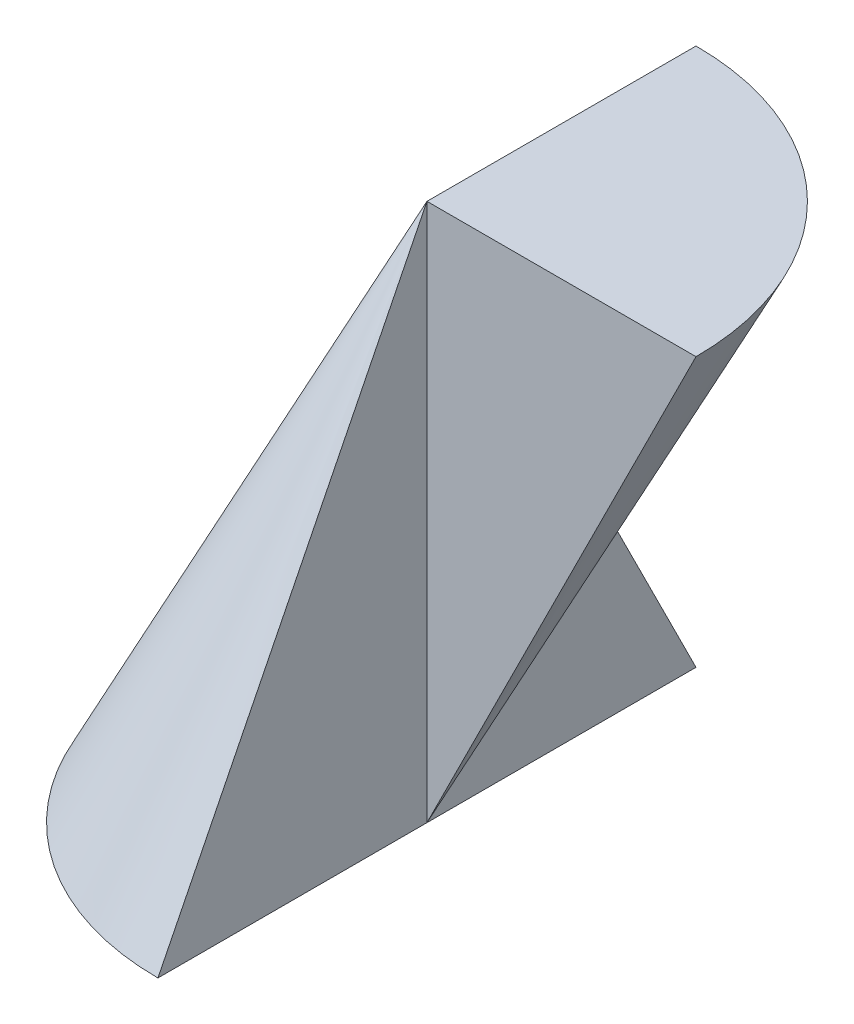
from build123d import *

# Parameters (mm, degrees)
REVOLVE1_ANGLE = 180
REVOLVE2_ANGLE = 90


with BuildPart() as part:
    # Sketch1 → Revolve1 (revolve)
    with BuildSketch(Plane(origin=(0, 0, 0), x_dir=(0, 0, -1), z_dir=(1, 0, 0))):
        Polygon((0, 0), (2, 0), (0, 4), align=None)
    revolve(axis=Axis((0, 4, 0), (0, 1, 0)), revolution_arc=REVOLVE1_ANGLE)

    # Sketch2 → Revolve2 (revolve)
    with BuildSketch(Plane(origin=(0, 0, 0), x_dir=(0, 0, -1), z_dir=(1, 0, 0))):
        Polygon((0, 0), (2, 4), (0, 4), align=None)
    revolve(axis=Axis((0, 4, 0), (0, -1, 0)), revolution_arc=REVOLVE2_ANGLE)


solid = part.part
